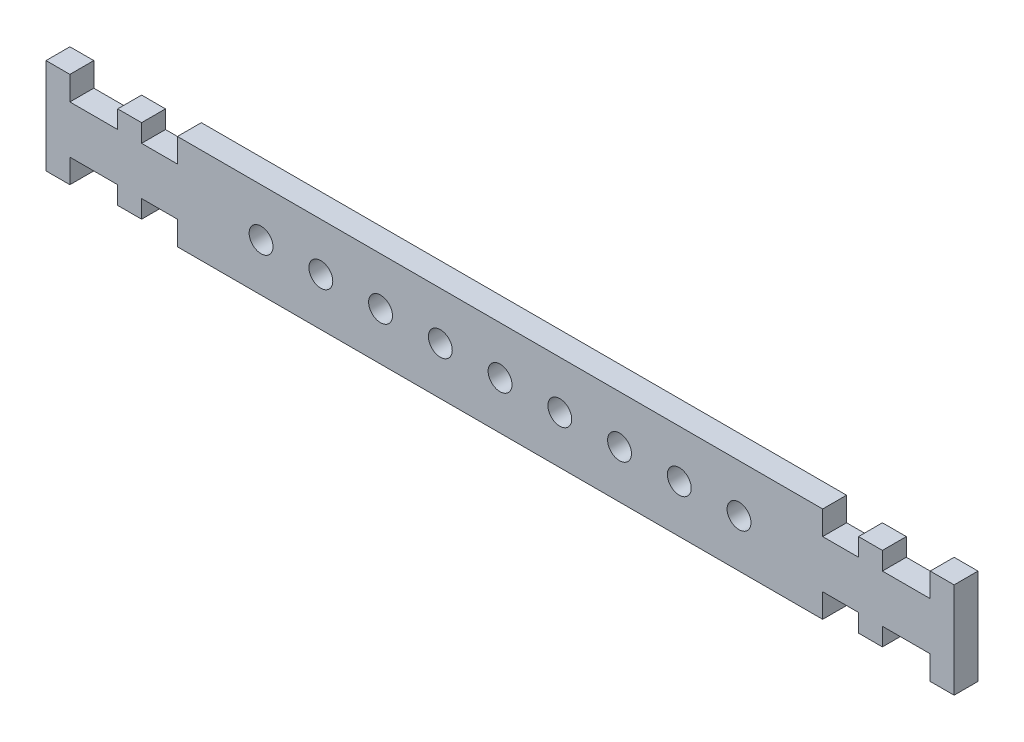
from build123d import *

# Parameters (mm, degrees)
SKETCH_1_R      = 1
EXTRUDE_1_DEPTH = 2


with BuildPart() as part:
    # 草图1 → 凸台-拉伸1 (new body)
    with BuildSketch(Plane.XY):
        Polygon((-27, 4), (27, 4), (27, 2), (30, 2), (30, 3.5), (32, 3.5), (32, 2), (36, 2), (36, 4), (38, 4), (38, -4), (36, -4), (36, -2), (32, -2), (32, -3.5), (30, -3.5), (30, -2), (27, -2), (27, -4), (-27, -4), (-27, -2), (-30, -2), (-30, -3.5), (-32, -3.5), (-32, -2), (-36, -2), (-36, -4), (-38, -4), (-38, 4), (-36, 4), (-36, 2), (-32, 2), (-32, 3.5), (-30, 3.5), (-30, 2), (-27, 2), align=None)
        Circle(SKETCH_1_R, mode=Mode.SUBTRACT)
        with Locations((5, 0)):
            Circle(SKETCH_1_R, mode=Mode.SUBTRACT)
        with Locations((10, 0)):
            Circle(SKETCH_1_R, mode=Mode.SUBTRACT)
        with Locations((15, 0)):
            Circle(SKETCH_1_R, mode=Mode.SUBTRACT)
        with Locations((20, 0)):
            Circle(SKETCH_1_R, mode=Mode.SUBTRACT)
        with Locations((-5, 0)):
            Circle(SKETCH_1_R, mode=Mode.SUBTRACT)
        with Locations((-10, 0)):
            Circle(SKETCH_1_R, mode=Mode.SUBTRACT)
        with Locations((-15, 0)):
            Circle(SKETCH_1_R, mode=Mode.SUBTRACT)
        with Locations((-20, 0)):
            Circle(SKETCH_1_R, mode=Mode.SUBTRACT)
    extrude(amount=EXTRUDE_1_DEPTH)


solid = part.part
